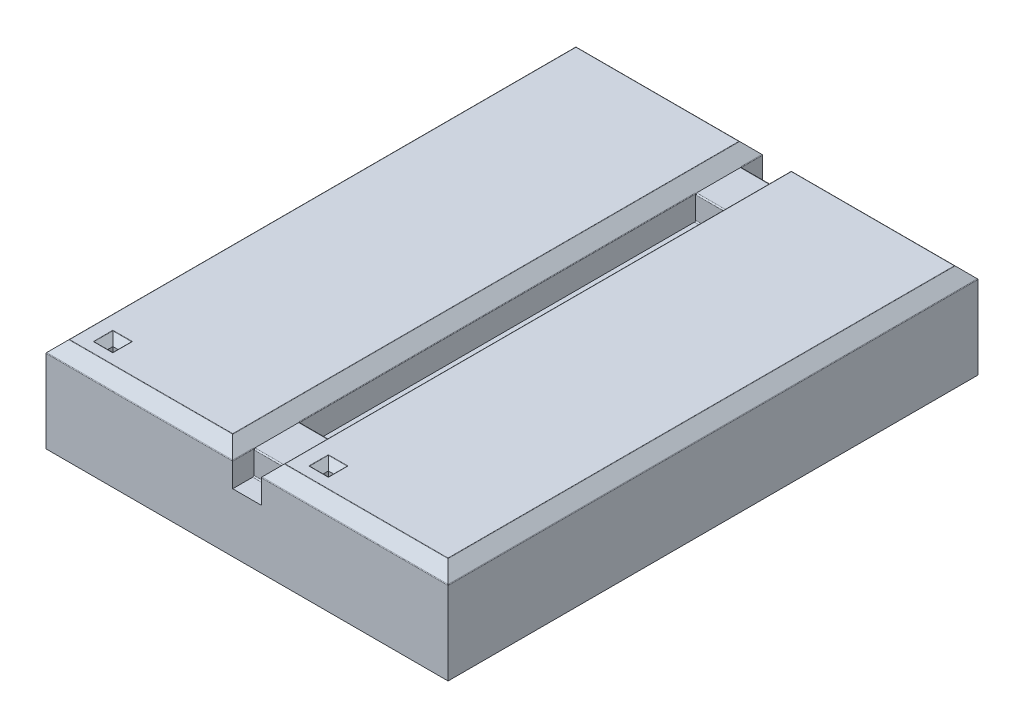
from build123d import *

# Parameters (mm, degrees)
SKETCH1_W           = 34.6
SKETCH1_H           = 45.6
BOSS_EXTRUDE1_DEPTH = 8.15
SKETCH2_W           = 2.47
SKETCH2_H           = 45.6
CUT_EXTRUDE1_DEPTH  = 3.09
CHAMFER1_SIZE       = 1
SKETCH3_W           = 2.47
SKETCH3_H           = 3.95
BOSS_EXTRUDE2_DEPTH = 2.09
SKETCH4_W           = 0.45
SKETCH4_H           = 0.45
CUT_EXTRUDE2_DEPTH  = 7.09
CHAMFER2_SIZE       = 0.6
FILLET2_R           = 0.05
FILLET3_R           = 0.1
FILLET4_R           = 0.1


with BuildPart() as part:
    # Sketch1 → Boss-Extrude1 (new body)
    with BuildSketch(Plane(origin=(0, 0, 0), x_dir=(1, 0, 0), z_dir=(0, 1, 0))):
        Rectangle(SKETCH1_W, SKETCH1_H)
    extrude(amount=BOSS_EXTRUDE1_DEPTH)

    # Sketch2 → Cut-Extrude1 (cut)
    with BuildSketch(Plane(origin=(0, 8.15, 0), x_dir=(1, 0, 0), z_dir=(0, 1, 0))):
        Rectangle(SKETCH2_W, SKETCH2_H)
    extrude(amount=-CUT_EXTRUDE1_DEPTH, mode=Mode.SUBTRACT)

    # Chamfer1
    chamfer1_edges = [part.edges().sort_by_distance(p)[0] for p in [
        (-17.3, 8.15, 0),
        (-9.2675, 8.15, 22.8),
        (-9.2675, 8.15, -22.8),
        (9.2675, 8.15, 22.8),
        (1.235, 8.15, 0),
        (-1.235, 8.15, 0),
        (17.3, 8.15, 0),
        (9.2675, 8.15, -22.8),
    ]]
    chamfer(chamfer1_edges, length=CHAMFER1_SIZE)

    # Sketch3 → Boss-Extrude2 (add)
    with BuildSketch(Plane(origin=(0, 5.06, 0), x_dir=(1, 0, 0), z_dir=(0, 1, 0))):
        with Locations((0, 19.005)):
            Rectangle(SKETCH3_W, SKETCH3_H)
        with Locations((0, -19.005)):
            Rectangle(SKETCH3_W, SKETCH3_H)
    extrude(amount=BOSS_EXTRUDE2_DEPTH)

    # Sketch4 → Cut-Extrude2 (cut)
    with BuildSketch(Plane(origin=(0, 8.15, 0), x_dir=(1, 0, 0), z_dir=(0, 1, 0))):
        with Locations((-14.275, -20.075)):
            Rectangle(SKETCH4_W, SKETCH4_H)
        with Locations((4.275, -20.075)):
            Rectangle(SKETCH4_W, SKETCH4_H)
    extrude(amount=-CUT_EXTRUDE2_DEPTH, mode=Mode.SUBTRACT)

    # Chamfer2
    chamfer2_edges = [part.edges().sort_by_distance(p)[0] for p in [
        (-14.05, 8.15, 20.075),
        (-14.275, 8.15, 19.85),
        (-14.5, 8.15, 20.075),
        (-14.275, 8.15, 20.3),
        (4.275, 8.15, 19.85),
        (4.05, 8.15, 20.075),
        (4.275, 8.15, 20.3),
        (4.5, 8.15, 20.075),
    ]]
    chamfer(chamfer2_edges, length=CHAMFER2_SIZE)

    # Fillet2
    fillet2_edges = [part.edges().sort_by_distance(p)[0] for p in [
        (2.235, 8.15, 0),
        (9.2675, 8.15, 21.8),
        (16.3, 8.15, 0),
        (9.2675, 8.15, -21.8),
        (-2.235, 8.15, 0),
        (-9.2675, 8.15, -21.8),
        (-16.3, 8.15, 0),
        (-9.2675, 8.15, 21.8),
        (3.45, 8.15, 20.075),
        (4.275, 8.15, 19.25),
        (5.1, 8.15, 20.075),
        (4.275, 8.15, 20.9),
        (-14.275, 8.15, 19.25),
        (-15.1, 8.15, 20.075),
        (-13.45, 8.15, 20.075),
        (-14.275, 8.15, 20.9),
    ]]
    fillet(fillet2_edges, radius=FILLET2_R)

    # Fillet3
    fillet3_edges = [part.edges().sort_by_distance(p)[0] for p in [
        (-9.2675, 7.15, -22.8),
        (9.2675, 7.15, -22.8),
        (17.3, 7.15, 0),
        (-9.2675, 7.15, 22.8),
        (9.2675, 7.15, 22.8),
        (1.235, 7.15, 21.89),
        (-17.3, 7.15, 0),
        (-1.235, 7.15, -21.89),
        (-1.235, 7.15, 0),
        (1.235, 7.15, -21.89),
        (-1.235, 7.15, 21.89),
        (1.235, 7.15, 0),
    ]]
    fillet(fillet3_edges, radius=FILLET3_R)

    # Fillet4
    fillet4_edges = [part.edges().sort_by_distance(p)[0] for p in [
        (0, 5.06, -20.98),
        (0, 5.06, -17.03),
        (0, 7.15, -20.98),
        (0, 7.15, -17.03),
        (0, 5.06, 17.03),
        (0, 5.06, 20.98),
        (0, 7.15, 17.03),
        (0, 7.15, 20.98),
    ]]
    fillet(fillet4_edges, radius=FILLET4_R)


solid = part.part
